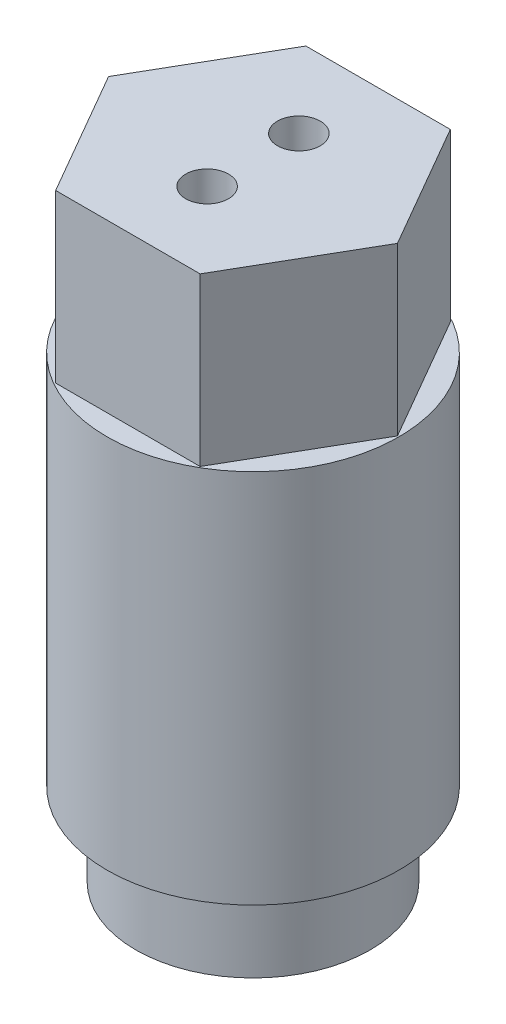
from build123d import *

# Parameters (mm, degrees)
MAIN_BODY_PROFILE_R     = 11.1125
MAIN_BODY_EXTRUDE_DEPTH = 28.575
HEXAGON_BODY_DEPTH      = 12.7
TIP_PROFILE_R           = 8.9281
TIP_BODY_DEPTH          = 6.35
BACK_POWDER_HOLE_D      = 12.7
BACK_POWDER_HOLE_DEPTH  = 31.109535069
BACK_POWDER_HOLE_TIP    = 3.815464931
SCREW_HOLES_AT_2_COUNT  = 2
SCREW_HOLES_AT_2_PITCH  = 6.985
SKETCH12_R              = 2.8575
THROUGH_HOLES_DEPTH     = 41.246641376


with BuildPart() as part:
    # Main Body Profile → Main Body Extrude (new body)
    with BuildSketch(Plane(origin=(0, 0, 0), x_dir=(1, 0, 0), z_dir=(0, 1, 0))):
        Circle(MAIN_BODY_PROFILE_R)
    extrude(amount=MAIN_BODY_EXTRUDE_DEPTH)

    # Hexagon Profile → Hexagon Body (add)
    with BuildSketch(Plane(origin=(0, 28.575, 0), x_dir=(1, 0, 0), z_dir=(0, 1, 0))):
        Polygon((5.499261314, 9.525), (-5.499261314, 9.525), (-10.998522628, 0), (-5.499261314, -9.525), (5.499261314, -9.525), (10.998522628, 0), align=None)
    extrude(amount=HEXAGON_BODY_DEPTH)

    # Tip Profile → Tip Body (add)
    with BuildSketch(Plane.XZ):
        Circle(TIP_PROFILE_R)
    extrude(amount=TIP_BODY_DEPTH)

    # Back Powder Hole
    with Locations(Plane(origin=(0, -6.35, 0), x_dir=(-1, 0, 0), z_dir=(0, -1, 0))):
        with Locations((0, 0)):
            Hole(BACK_POWDER_HOLE_D / 2, depth=BACK_POWDER_HOLE_DEPTH)
            with Locations((0, 0, -(BACK_POWDER_HOLE_DEPTH + BACK_POWDER_HOLE_TIP / 2))):  # 118° drill point
                Cone(0, BACK_POWDER_HOLE_D / 2, BACK_POWDER_HOLE_TIP, mode=Mode.SUBTRACT)

    # Sketch11 → Screw Holes (revolve, cut)
    with BuildSketch(Plane(origin=(0, 33.896641376, 3.4925), x_dir=(0, 0, -1), z_dir=(1, 0, 0))):
        Polygon((0, 0), (0, 7.378358624), (1.63195, 7.378358624), (1.63195, 1.028358553), (2.8575, 0), align=None)
    screw_holes = revolve(axis=Axis((0, 27.546641376, 3.4925), (0, 1, 0)), mode=Mode.SUBTRACT)

    # Screw Holes at 2: Screw Holes ×2
    with Locations(*[(0, 0, -i * SCREW_HOLES_AT_2_PITCH) for i in range(1, SCREW_HOLES_AT_2_COUNT)]):
        add(screw_holes, mode=Mode.SUBTRACT)

    # Sketch12 → Through Holes (cut, through all)
    with BuildSketch(Plane(origin=(0, 33.896641376, 0), x_dir=(1, 0, 0), z_dir=(0, 1, 0))):
        with Locations((0, 3.4925)):
            Circle(SKETCH12_R)
        with Locations((0, -3.4925)):
            Circle(SKETCH12_R)
    extrude(amount=-THROUGH_HOLES_DEPTH, mode=Mode.SUBTRACT)

    # Sketch13 → Revolved Cut (revolve, cut)
    with BuildSketch(Plane.XY):
        Polygon((-8.9281, 0), (-7.696200006, 0), (-8.9281, -0.7112378), align=None)
    revolve(axis=Axis((0, 0, 0), (0, -1, 0)), mode=Mode.SUBTRACT)


solid = part.part
